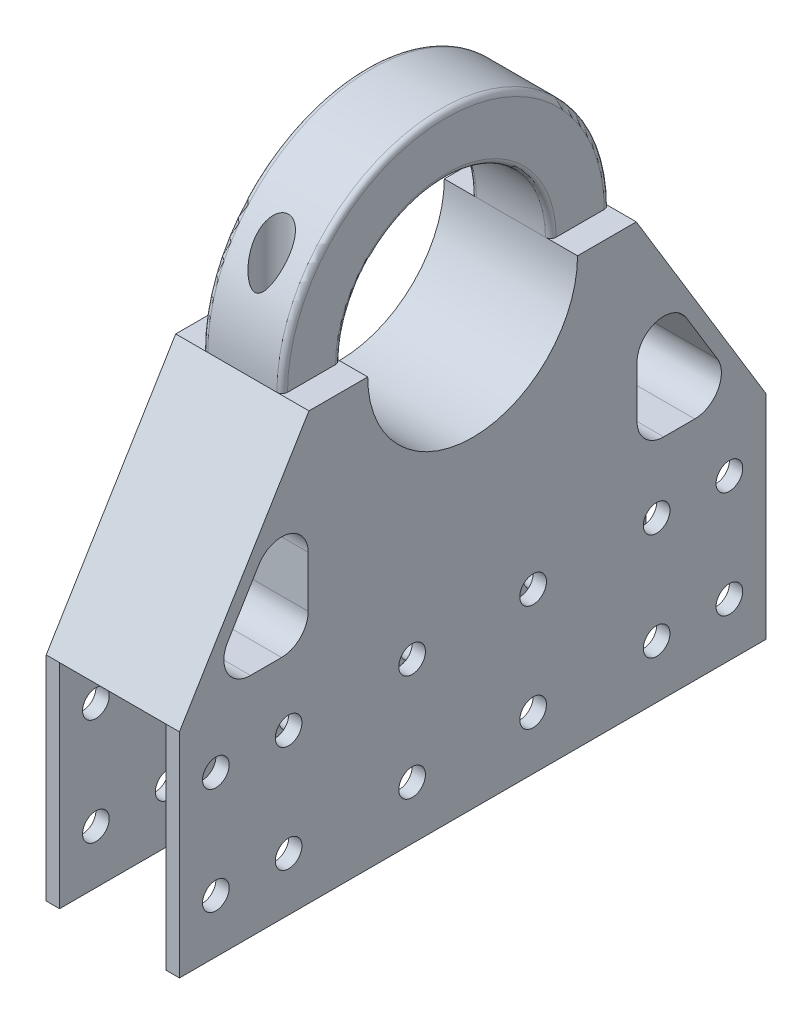
from build123d import *

# Parameters (mm, degrees)
SKETCH1_R           = 3.175
BOSS_EXTRUDE1_DEPTH = 3.175
BOSS_EXTRUDE2_START = 3.175
BOSS_EXTRUDE2_DEPTH = 25.4
SKETCH2_R           = 4
CUT_EXTRUDE1_DEPTH  = 51.8
CUT_EXTRUDE4_DEPTH  = 29.575
FILLET1_R           = 6.35
SKETCH7_R           = 3.175
BOSS_EXTRUDE3_DEPTH = 3.175
BOSS_EXTRUDE4_START = -15.875
BOSS_EXTRUDE4_DEPTH = 9.5
SKETCH10_R          = 4
CUT_EXTRUDE8_DEPTH  = 40
FILLET3_R           = 1.27


with BuildPart() as part:
    # Sketch1 → Boss-Extrude1 (new body)
    with BuildSketch(Plane(origin=(0, 0, 0), x_dir=(0, 0, -1), z_dir=(1, 0, 0))):
        with BuildLine():
            Line((-25, 0), (-39, 0))
            Line((-39, 0), (-69.85, -50.8))
            Line((-69.85, -50.8), (-69.85, -101.6))
            Line((-69.85, -101.6), (69.85, -101.6))
            Line((69.85, -101.6), (69.85, -50.8))
            Line((69.85, -50.8), (39, 0))
            Line((39, 0), (25, 0))
            ThreePointArc((25, 0), (0, -25), (-25, 0))
        make_face()
        with Locations((-61.18125, -63.5)):
            Circle(SKETCH1_R, mode=Mode.SUBTRACT)
        with Locations((-43.84375, -63.5)):
            Circle(SKETCH1_R, mode=Mode.SUBTRACT)
        with Locations((-61.18125, -88.9)):
            Circle(SKETCH1_R, mode=Mode.SUBTRACT)
        with Locations((-43.84375, -88.9)):
            Circle(SKETCH1_R, mode=Mode.SUBTRACT)
        with Locations((61.18125, -88.9)):
            Circle(SKETCH1_R, mode=Mode.SUBTRACT)
        with Locations((43.84375, -88.9)):
            Circle(SKETCH1_R, mode=Mode.SUBTRACT)
        with Locations((43.84375, -63.5)):
            Circle(SKETCH1_R, mode=Mode.SUBTRACT)
        with Locations((61.18125, -63.5)):
            Circle(SKETCH1_R, mode=Mode.SUBTRACT)
        with Locations((-14.4125, -63.5)):
            Circle(SKETCH1_R, mode=Mode.SUBTRACT)
        with Locations((14.4125, -63.5)):
            Circle(SKETCH1_R, mode=Mode.SUBTRACT)
        with Locations((-14.4125, -88.9)):
            Circle(SKETCH1_R, mode=Mode.SUBTRACT)
        with Locations((14.4125, -88.9)):
            Circle(SKETCH1_R, mode=Mode.SUBTRACT)
    extrude(amount=BOSS_EXTRUDE1_DEPTH)

    # Sketch1_3 → Boss-Extrude2 (add)
    with BuildSketch(Plane(origin=(0, 0, 0), x_dir=(0, 0, -1), z_dir=(1, 0, 0)).offset(BOSS_EXTRUDE2_START)):
        with BuildLine():
            ThreePointArc((-25, 0), (0, -25), (25, 0))
            Line((25, 0), (39, 0))
            Line((39, 0), (69.85, -50.8))
            Line((69.85, -50.8), (-69.85, -50.8))
            Line((-69.85, -50.8), (-39, 0))
            Line((-39, 0), (-25, 0))
        make_face()
    extrude(amount=BOSS_EXTRUDE2_DEPTH)

    # Sketch2 → Cut-Extrude1 (cut, through all)
    with BuildSketch(Plane.XZ.offset(50.8)):
        with Locations((15.875, 32.000000008)):
            Circle(SKETCH2_R)
        with Locations((15.875, -32.000000008)):
            Circle(SKETCH2_R)
    extrude(amount=-CUT_EXTRUDE1_DEPTH, mode=Mode.SUBTRACT)

    # Sketch3 → Cut-Extrude4 (cut, through all)
    with BuildSketch(Plane(origin=(28.575, 0, 0), x_dir=(0, 0, -1), z_dir=(1, 0, 0))):
        Polygon((-39.175000008, -47.625), (-64.207269904, -47.625), (-39.175000008, -6.404925098), align=None)
        Polygon((39.175000008, -47.625), (64.207269904, -47.625), (39.175000008, -6.404925098), align=None)
    extrude(amount=-CUT_EXTRUDE4_DEPTH, mode=Mode.SUBTRACT)

    # Fillet1
    fillet1_edges = [part.edges().sort_by_distance(p)[0] for p in [
        (14.2875, -47.625, -64.207269904),
        (14.2875, -47.625, -39.175000008),
        (14.2875, -6.404925098, -39.175000008),
        (14.2875, -47.625, 39.175000008),
        (14.2875, -47.625, 64.207269904),
        (14.2875, -6.404925098, 39.175000008),
    ]]
    fillet(fillet1_edges, radius=FILLET1_R)

    # Sketch7 → Boss-Extrude3 (add)
    with BuildSketch(Plane(origin=(28.575, 0, 0), x_dir=(0, 0, -1), z_dir=(1, 0, 0))):
        with BuildLine():
            Line((-69.85, -101.6), (-69.85, -50.8))
            Line((-69.85, -50.8), (-39, 0))
            Line((-39, 0), (-25, 0))
            ThreePointArc((-25, 0), (0, -25), (25, 0))
            Line((25, 0), (39, 0))
            Line((39, 0), (69.85, -50.8))
            Line((69.85, -50.8), (69.85, -101.6))
            Line((69.85, -101.6), (-69.85, -101.6))
        make_face()
        with Locations((-43.84375, -88.9)):
            Circle(SKETCH7_R, mode=Mode.SUBTRACT)
        with Locations((-61.18125, -88.9)):
            Circle(SKETCH7_R, mode=Mode.SUBTRACT)
        with Locations((-61.18125, -63.5)):
            Circle(SKETCH7_R, mode=Mode.SUBTRACT)
        with Locations((-43.84375, -63.5)):
            Circle(SKETCH7_R, mode=Mode.SUBTRACT)
        with Locations((14.4125, -88.9)):
            Circle(SKETCH7_R, mode=Mode.SUBTRACT)
        with Locations((-14.4125, -88.9)):
            Circle(SKETCH7_R, mode=Mode.SUBTRACT)
        with Locations((-14.4125, -63.5)):
            Circle(SKETCH7_R, mode=Mode.SUBTRACT)
        with Locations((14.4125, -63.5)):
            Circle(SKETCH7_R, mode=Mode.SUBTRACT)
        with Locations((61.18125, -88.9)):
            Circle(SKETCH7_R, mode=Mode.SUBTRACT)
        with Locations((43.84375, -88.9)):
            Circle(SKETCH7_R, mode=Mode.SUBTRACT)
        with Locations((43.84375, -63.5)):
            Circle(SKETCH7_R, mode=Mode.SUBTRACT)
        with Locations((61.18125, -63.5)):
            Circle(SKETCH7_R, mode=Mode.SUBTRACT)
        with BuildLine():
            Line((58.349371858, -37.978931256), (50.952562153, -25.798771352))
            ThreePointArc((50.952562153, -25.798771352), (43.813643765, -22.979796367), (39.175000008, -29.094840096))
            Line((39.175000008, -29.094840096), (39.175000008, -41.275))
            ThreePointArc((39.175000008, -41.275), (41.034871947, -45.765128061), (45.525000008, -47.625))
            Line((45.525000008, -47.625), (52.921809713, -47.625))
            ThreePointArc((52.921809713, -47.625), (58.455910206, -44.388877284), (58.349371858, -37.978931256))
        make_face(mode=Mode.SUBTRACT)
        with BuildLine():
            Line((-45.525000008, -47.625), (-52.921809713, -47.625))
            ThreePointArc((-52.921809713, -47.625), (-58.455910206, -44.388877284), (-58.349371858, -37.978931256))
            Line((-58.349371858, -37.978931256), (-50.952562153, -25.798771352))
            ThreePointArc((-50.952562153, -25.798771352), (-43.813643765, -22.979796367), (-39.175000008, -29.094840096))
            Line((-39.175000008, -29.094840096), (-39.175000008, -41.275))
            ThreePointArc((-39.175000008, -41.275), (-41.034871947, -45.765128061), (-45.525000008, -47.625))
        make_face(mode=Mode.SUBTRACT)
    extrude(amount=BOSS_EXTRUDE3_DEPTH)


with BuildPart() as body_2:
    # Sketch9 → Boss-Extrude4 (new body, symmetric)
    with BuildSketch(Plane.ZY.offset(BOSS_EXTRUDE4_START)):
        with BuildLine():
            Line((-39, 0), (-25, 0))
            ThreePointArc((-25, 0), (0, 25), (25, 0))
            Line((25, 0), (39, 0))
            ThreePointArc((39, 0), (0, 39), (-39, 0))
        make_face()
    extrude(amount=BOSS_EXTRUDE4_DEPTH, both=True)

    # Sketch10 → Cut-Extrude8 (cut, through all)
    with BuildSketch(Plane(origin=(0, 0, 0), x_dir=(1, 0, 0), z_dir=(0, 1, 0))):
        with Locations((15.875, 32.000000008)):
            Circle(SKETCH10_R)
        with Locations((15.875, -32.000000008)):
            Circle(SKETCH10_R)
    extrude(amount=CUT_EXTRUDE8_DEPTH, mode=Mode.SUBTRACT)

    # Fillet3
    fillet3_edges = [body_2.edges().sort_by_distance(p)[0] for p in [
        (6.375, 39, 0),
        (6.375, 25, 0),
        (25.375, 39, 0),
        (25.375, 25, 0),
    ]]
    fillet(fillet3_edges, radius=FILLET3_R)


solid = Compound([part.part, body_2.part])
